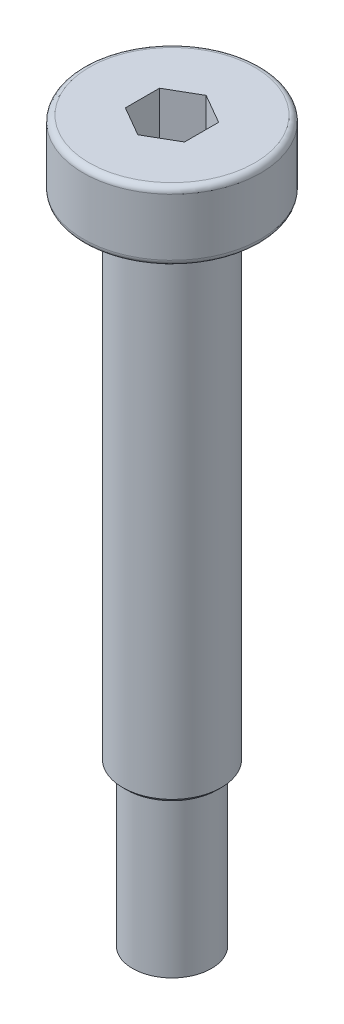
from build123d import *

# Parameters (mm, degrees)
FILLET1_R          = 0.3
CUT_EXTRUDE1_DEPTH = 2.4
CHAMFER1_SIZE      = 0.2


with BuildPart() as part:
    # Sketch1 → Revolve1 (revolve)
    with BuildSketch(Plane.XY):
        Polygon((0, 3.5), (-4.5, 3.5), (-4.5, 0), (-2.5, 0), (-2.5, -25), (-2, -25), (-2, -33), (0, -33), align=None)
    revolve(axis=Axis((0, 3.5, 0), (0, -1, 0)))

    # Fillet1
    fillet1_edges = [part.edges().sort_by_distance(p)[0] for p in [
        (4.5, 0, 0),
        (4.5, 3.5, 0),
    ]]
    fillet(fillet1_edges, radius=FILLET1_R)

    # Sketch2 → Cut-Extrude1 (cut)
    with BuildSketch(Plane(origin=(0, 3.5, 0), x_dir=(1, 0, 0), z_dir=(0, 1, 0))):
        Polygon((1.5, 0.866025404), (0, 1.732050808), (-1.5, 0.866025404), (-1.5, -0.866025404), (0, -1.732050808), (1.5, -0.866025404), align=None)
    extrude(amount=-CUT_EXTRUDE1_DEPTH, mode=Mode.SUBTRACT)

    # Chamfer1
    chamfer1_edges = [part.edges().sort_by_distance(p)[0] for p in [
        (2.5, -25, 0),
    ]]
    chamfer(chamfer1_edges, length=CHAMFER1_SIZE)


solid = part.part
